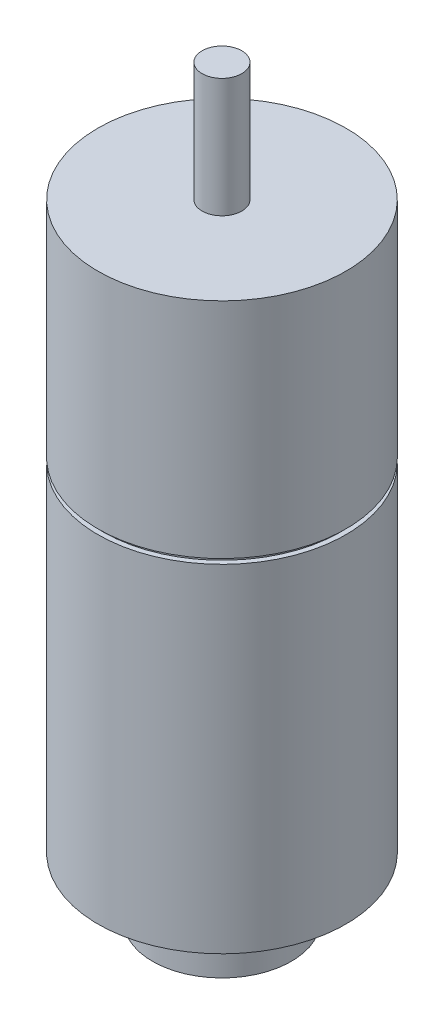
from build123d import *


with BuildPart() as part:
    # Esboço1 → Revolução1 (revolve)
    with BuildSketch(Plane.XY):
        Polygon((0, 0), (7, 0), (7, 5), (6, 5), (6, 6), (12.5, 6), (12.5, 40), (12, 40), (12, 40.5), (12.5, 40.5), (12.5, 63), (2, 63), (2, 75), (0, 75), align=None)
    revolve(axis=Axis((0, 75, 0), (0, -1, 0)))


solid = part.part
